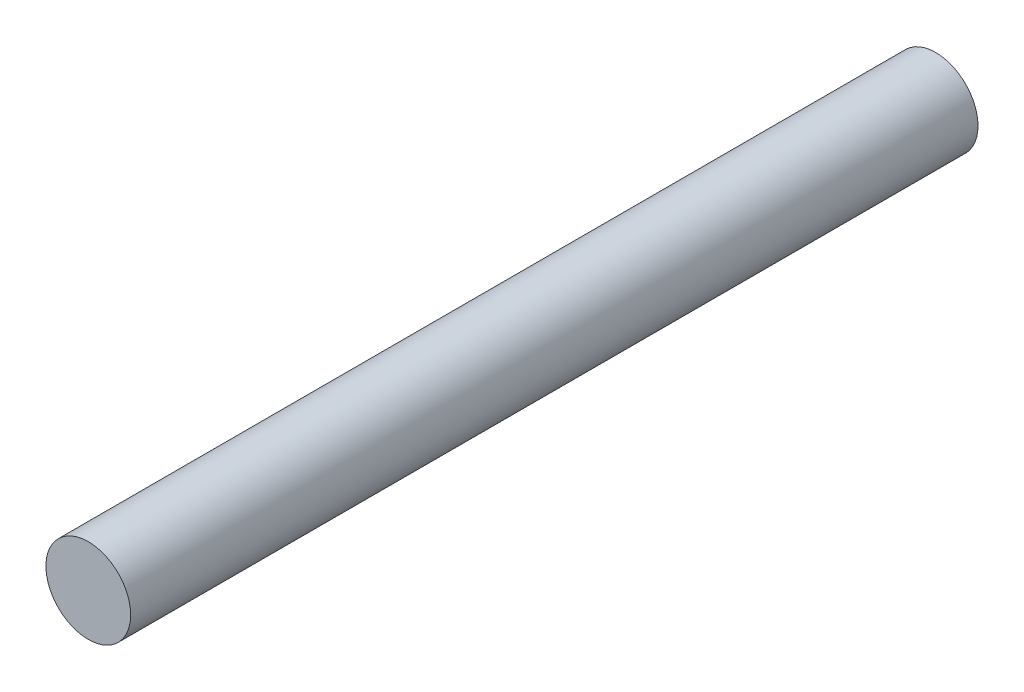
from build123d import *

# Parameters (mm, degrees)
SKETCH1_R           = 4
BOSS_EXTRUDE1_DEPTH = 80


with BuildPart() as part:
    # Sketch1 → Boss-Extrude1 (new body)
    with BuildSketch(Plane.XY):
        Circle(SKETCH1_R)
    extrude(amount=BOSS_EXTRUDE1_DEPTH)


solid = part.part
